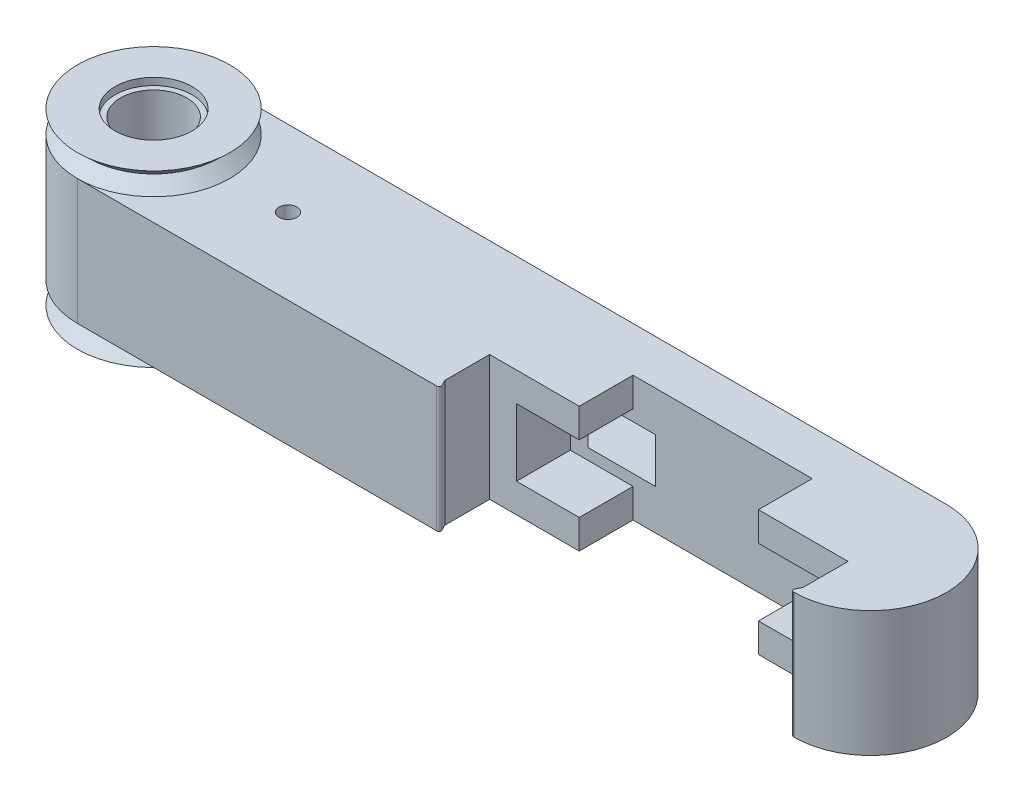
from build123d import *

# Parameters (mm, degrees)
EXTRUDE_1_DEPTH     = 14
SKETCH_3_R          = 3.7
CUT_EXTRUDE_1_DEPTH = 19
SKETCH_5_R          = 4.3
CUT_EXTRUDE_2_DEPTH = 0.8
SKETCH_6_R          = 4.3
CUT_EXTRUDE_3_DEPTH = 0.8
SKETCH_8_W          = 40
SKETCH_8_H          = 14
CUT_EXTRUDE_4_DEPTH = 12
SKETCH_9_W          = 2.5
SKETCH_9_H          = 5
CUT_EXTRUDE_5_DEPTH = 5
CUT_EXTRUDE_6_DEPTH = 5
EXTRUDE_3_DEPTH     = 6
EXTRUDE_5_DEPTH     = 14
FILLET_5_R          = 0.25
SKETCH_15_R         = 1
CUT_EXTRUDE_7_DEPTH = 14


with BuildPart() as part:
    # 스케치1 → 보스-돌출1 (new body)
    with BuildSketch(Plane(origin=(0, 0, 0), x_dir=(1, 0, 0), z_dir=(0, 1, 0))):
        with BuildLine():
            Line((0, 8.5), (80, 8.5))
            ThreePointArc((80, 8.5), (88.5, 0), (80, -8.5))
            Line((80, -8.5), (0, -8.5))
            ThreePointArc((0, -8.5), (-8.5, 0), (0, 8.5))
        make_face()
    extrude(amount=EXTRUDE_1_DEPTH)

    # 스케치2 → 회전1 (revolve)
    with BuildSketch(Plane(origin=(0, 0, 0), x_dir=(0, 0, -1), z_dir=(1, 0, 0))):
        Polygon((0, 14), (0, 16.5), (8.5, 16.5), (7.15, 15.25), (8.5, 14), align=None)
        Polygon((0, 0), (0, -2.5), (8.5, -2.5), (7.15, -1.25), (8.5, 0), align=None)
    revolve(axis=Axis((0, 14, 0), (0, -1, 0)))

    # 스케치3 → 컷-돌출1 (cut)
    with BuildSketch(Plane(origin=(0, 16.5, 0), x_dir=(1, 0, 0), z_dir=(0, 1, 0))):
        Circle(SKETCH_3_R)
    extrude(amount=-CUT_EXTRUDE_1_DEPTH, mode=Mode.SUBTRACT)

    # 스케치5 → 컷-돌출2 (cut)
    with BuildSketch(Plane(origin=(0, 16.5, 0), x_dir=(1, 0, 0), z_dir=(0, 1, 0))):
        Circle(SKETCH_5_R)
    extrude(amount=-CUT_EXTRUDE_2_DEPTH, mode=Mode.SUBTRACT)

    # 스케치6 → 컷-돌출3 (cut)
    with BuildSketch(Plane.XZ.offset(2.5)):
        Circle(SKETCH_6_R)
    extrude(amount=-CUT_EXTRUDE_3_DEPTH, mode=Mode.SUBTRACT)

    # 스케치8 → 컷-돌출4 (cut)
    with BuildSketch(Plane.XY.offset(8.5)):
        with Locations((60, 7)):
            Rectangle(SKETCH_8_W, SKETCH_8_H)
    extrude(amount=-CUT_EXTRUDE_4_DEPTH, mode=Mode.SUBTRACT)

    # 스케치9 → 컷-돌출5 (cut)
    with BuildSketch(Plane.XY.offset(-3.5)):
        with Locations((46.25, 7)):
            Rectangle(SKETCH_9_W, SKETCH_9_H)
    extrude(amount=-CUT_EXTRUDE_5_DEPTH, mode=Mode.SUBTRACT)

    # 스케치11 → 컷-돌출6 (cut)
    with BuildSketch(Plane(origin=(0, 4.5, 0), x_dir=(1, 0, 0), z_dir=(0, 1, 0))):
        Polygon((47.5, 3.5), (52.5, 3.5), (47.5, 8.5), (40, 8.5), (45, 3.5), align=None)
    extrude(amount=CUT_EXTRUDE_6_DEPTH, mode=Mode.SUBTRACT)

    # 스케치12 → 보스-돌출3 (add)
    with BuildSketch(Plane.XY.offset(-3.5)):
        Polygon((80, 14), (70, 14), (70, 10.75), (77, 10.75), (77, 3.25), (70, 3.25), (70, 0), (80, 0), align=None)
        Polygon((50, 14), (50, 10.75), (43, 10.75), (43, 3.25), (50, 3.25), (50, 0), (40, 0), (40, 14), align=None)
    extrude(amount=EXTRUDE_3_DEPTH)

    # 스케치14 → 보스-돌출5 (add)
    with BuildSketch(Plane.XZ):
        Polygon((40, 8.5), (40.5, 8.5), (40, 7.5), align=None)
        Polygon((80, 8.5), (79.5, 8.5), (80, 7.5), align=None)
    extrude(amount=-EXTRUDE_5_DEPTH)

    # 필렛5
    fillet_5_edges = [part.edges().sort_by_distance(p)[0] for p in [
        (40.5, 7, 8.5),
        (79.5, 7, 8.5),
    ]]
    fillet(fillet_5_edges, radius=FILLET_5_R)

    # 스케치15 → 컷-돌출7 (cut)
    with BuildSketch(Plane(origin=(0, 14, 0), x_dir=(1, 0, 0), z_dir=(0, 1, 0))):
        with Locations((15, 0)):
            Circle(SKETCH_15_R)
    extrude(amount=-CUT_EXTRUDE_7_DEPTH, mode=Mode.SUBTRACT)


solid = part.part
